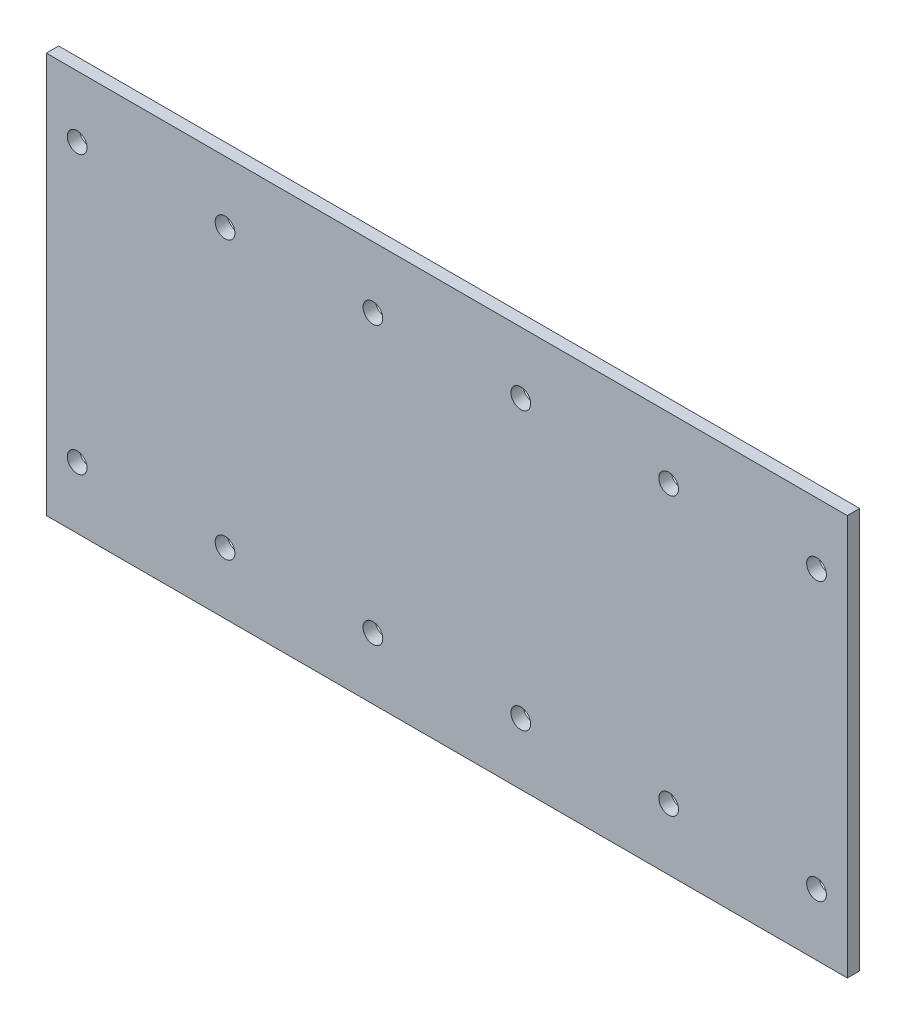
from build123d import *

# Parameters (mm, degrees)
ESQUISSE1_W        = 130
ESQUISSE1_H        = 65
ESQUISSE1_R        = 1.6
BOSS_EXTRU_1_DEPTH = 2


with BuildPart() as part:
    # Esquisse1 → Boss.-Extru.1 (new body)
    with BuildSketch(Plane.XY):
        with Locations((65, 32.5)):
            Rectangle(ESQUISSE1_W, ESQUISSE1_H)
        with Locations((125, 55)):
            Circle(ESQUISSE1_R, mode=Mode.SUBTRACT)
        with Locations((101, 55)):
            Circle(ESQUISSE1_R, mode=Mode.SUBTRACT)
        with Locations((77, 55)):
            Circle(ESQUISSE1_R, mode=Mode.SUBTRACT)
        with Locations((53, 55)):
            Circle(ESQUISSE1_R, mode=Mode.SUBTRACT)
        with Locations((29, 55)):
            Circle(ESQUISSE1_R, mode=Mode.SUBTRACT)
        with Locations((29, 10)):
            Circle(ESQUISSE1_R, mode=Mode.SUBTRACT)
        with Locations((53, 10)):
            Circle(ESQUISSE1_R, mode=Mode.SUBTRACT)
        with Locations((77, 10)):
            Circle(ESQUISSE1_R, mode=Mode.SUBTRACT)
        with Locations((101, 10)):
            Circle(ESQUISSE1_R, mode=Mode.SUBTRACT)
        with Locations((125, 10)):
            Circle(ESQUISSE1_R, mode=Mode.SUBTRACT)
        with Locations((5, 55)):
            Circle(ESQUISSE1_R, mode=Mode.SUBTRACT)
        with Locations((5, 10)):
            Circle(ESQUISSE1_R, mode=Mode.SUBTRACT)
    extrude(amount=BOSS_EXTRU_1_DEPTH)


solid = part.part
